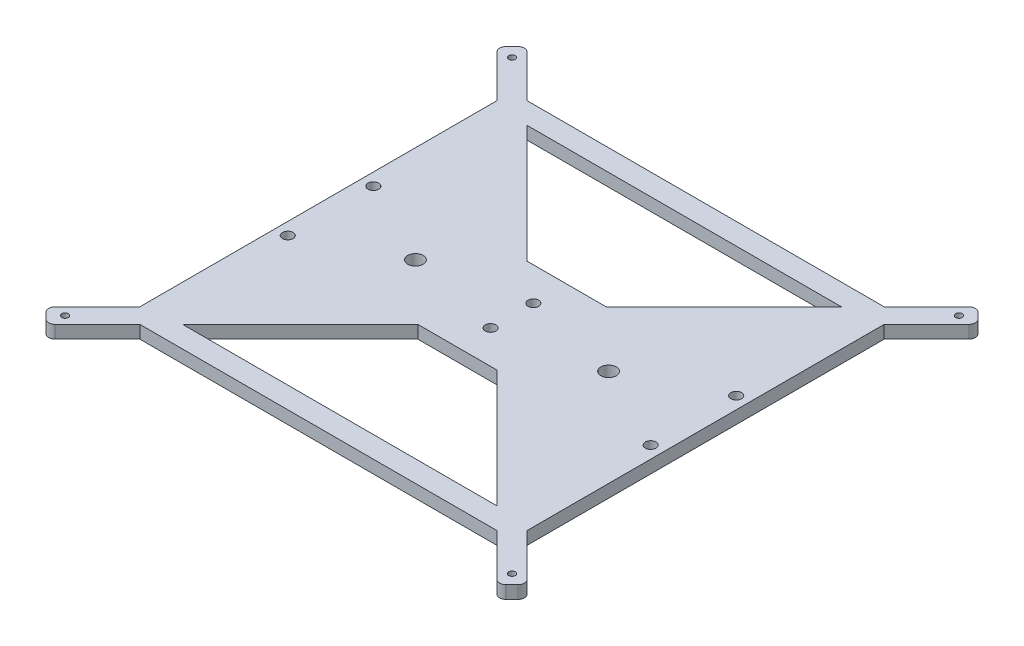
from build123d import *

# Parameters (mm, degrees)
BOSS_EXTRUDE2_DEPTH = 6
SKETCH1_6_R         = 1.55
CUT_EXTRUDE4_DEPTH  = 6
SKETCH2_R           = 2.5
SKETCH2_R_2         = 3.6
CUT_EXTRUDE5_DEPTH  = 6
SKETCH3_R           = 2.5
CUT_EXTRUDE6_DEPTH  = 6
CUT_EXTRUDE7_DEPTH  = 6


with BuildPart() as part:
    # Sketch1 → Boss-Extrude2 (new body)
    with BuildSketch(Plane(origin=(0, 0, 0), x_dir=(1, 0, 0), z_dir=(0, 1, 0))):
        with BuildLine():
            Line((-83.5, 90.571067812), (83.5, 90.571067812))
            Line((83.5, 90.571067812), (103.298989873, 110.370057685))
            ThreePointArc((103.298989873, 110.370057685), (105.420310217, 111.248737342), (107.54163056, 110.370057685))
            Line((107.54163056, 110.370057685), (110.370057685, 107.54163056))
            ThreePointArc((110.370057685, 107.54163056), (111.248737342, 105.420310217), (110.370057685, 103.298989873))
            Line((110.370057685, 103.298989873), (90.571067812, 83.5))
            Line((90.571067812, 83.5), (90.571067812, -83.5))
            Line((90.571067812, -83.5), (110.370057685, -103.298989873))
            ThreePointArc((110.370057685, -103.298989873), (111.248737342, -105.420310217), (110.370057685, -107.54163056))
            Line((110.370057685, -107.54163056), (107.54163056, -110.370057685))
            ThreePointArc((107.54163056, -110.370057685), (105.420310217, -111.248737342), (103.298989873, -110.370057685))
            Line((103.298989873, -110.370057685), (83.5, -90.571067812))
            Line((83.5, -90.571067812), (-83.5, -90.571067812))
            Line((-83.5, -90.571067812), (-103.298989873, -110.370057685))
            ThreePointArc((-103.298989873, -110.370057685), (-105.420310217, -111.248737342), (-107.54163056, -110.370057685))
            Line((-107.54163056, -110.370057685), (-110.370057685, -107.54163056))
            ThreePointArc((-110.370057685, -107.54163056), (-111.248737342, -105.420310217), (-110.370057685, -103.298989873))
            Line((-110.370057685, -103.298989873), (-90.571067812, -83.5))
            Line((-90.571067812, -83.5), (-90.571067812, 83.5))
            Line((-90.571067812, 83.5), (-110.370057685, 103.298989873))
            ThreePointArc((-110.370057685, 103.298989873), (-111.248737342, 105.420310217), (-110.370057685, 107.54163056))
            Line((-110.370057685, 107.54163056), (-107.54163056, 110.370057685))
            ThreePointArc((-107.54163056, 110.370057685), (-105.420310217, 111.248737342), (-103.298989873, 110.370057685))
            Line((-103.298989873, 110.370057685), (-83.5, 90.571067812))
        make_face()
    extrude(amount=BOSS_EXTRUDE2_DEPTH)

    # Sketch1_6 → Cut-Extrude4 (cut)
    with BuildSketch(Plane(origin=(0, 0, 0), x_dir=(1, 0, 0), z_dir=(0, 1, 0))):
        with Locations((-104.5, 104.5)):
            Circle(SKETCH1_6_R)
        with Locations((104.5, 104.5)):
            Circle(SKETCH1_6_R)
        with Locations((104.5, -104.5)):
            Circle(SKETCH1_6_R)
        with Locations((-104.5, -104.5)):
            Circle(SKETCH1_6_R)
    extrude(amount=CUT_EXTRUDE4_DEPTH, mode=Mode.SUBTRACT)

    # Sketch2 → Cut-Extrude5 (cut)
    with BuildSketch(Plane(origin=(0, 6, 0), x_dir=(1, 0, 0), z_dir=(0, 1, 0))):
        with Locations((-84.85, 20)):
            Circle(SKETCH2_R)
        with Locations((-84.85, -20)):
            Circle(SKETCH2_R)
        with Locations((45.15, 0)):
            Circle(SKETCH2_R_2)
        with Locations((84.85, -20)):
            Circle(SKETCH2_R)
        with Locations((-45.15, 0)):
            Circle(SKETCH2_R_2)
        with Locations((84.85, 20)):
            Circle(SKETCH2_R)
    extrude(amount=-CUT_EXTRUDE5_DEPTH, mode=Mode.SUBTRACT)

    # Sketch3 → Cut-Extrude6 (cut)
    with BuildSketch(Plane(origin=(0, 6, 0), x_dir=(1, 0, 0), z_dir=(0, 1, 0))):
        with Locations((0, 10)):
            Circle(SKETCH3_R)
        with Locations((0, -10)):
            Circle(SKETCH3_R)
    extrude(amount=-CUT_EXTRUDE6_DEPTH, mode=Mode.SUBTRACT)

    # Sketch4 → Cut-Extrude7 (cut)
    with BuildSketch(Plane(origin=(0, 6, 0), x_dir=(1, 0, 0), z_dir=(0, 1, 0))):
        Polygon((-73.5, 80.571067812), (73.5, 80.571067812), (18.5, 25.571067812), (-18.5, 25.571067812), align=None)
        Polygon((73.5, -80.571067812), (18.5, -25.571067812), (-18.5, -25.571067812), (-73.5, -80.571067812), align=None)
    extrude(amount=-CUT_EXTRUDE7_DEPTH, mode=Mode.SUBTRACT)


solid = part.part
